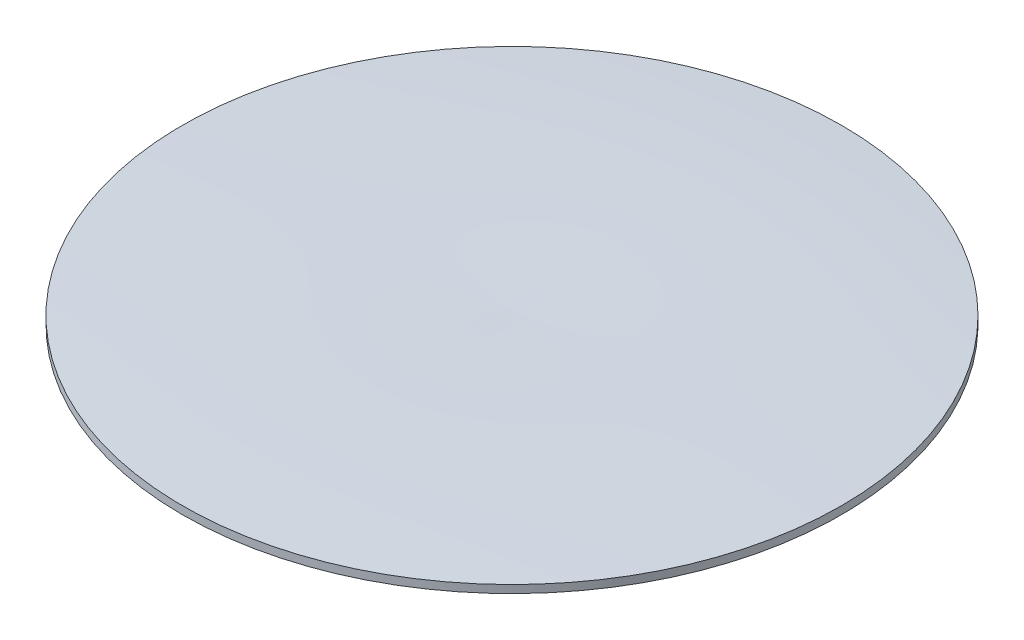
from build123d import *


with BuildPart() as part:
    # Sketch2 → Revolve1 (revolve)
    with BuildSketch(Plane.XY):
        with BuildLine():
            Line((0, 0), (84, 0))
            Line((84, 0), (84, 2))
            add(Edge.make_bspline(
                [(0, 3), (42.04721799, 4.491281307), (84, 2)],
                knots=[0, 0, 0, 1, 1, 1], degree=2))
            Line((0, 3), (0, 0))
        make_face()
    revolve(axis=Axis((0, 0, 0), (0, 1, 0)))


solid = part.part
